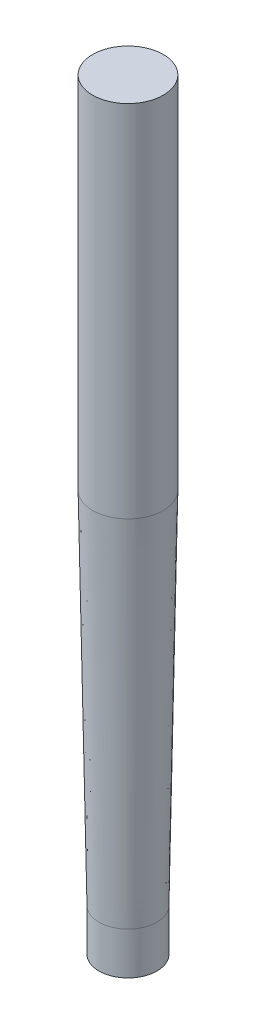
from build123d import *

# Parameters (mm, degrees)
CROQUIS2_R              = 8.341840259
SALIENTE_EXTRUIR1_DEPTH = 85
CROQUIS3_R              = 6.858159741
SALIENTE_EXTRUIR2_DEPTH = 10


with BuildPart() as part:
    # Croquis1 → Revolución1 (revolve)
    with BuildSketch(Plane(origin=(0, 0, 0), x_dir=(0, 0, -1), z_dir=(1, 0, 0))):
        Polygon((0, 0), (6.858159741, 0), (8.341840259, 85), (0, 85), align=None)
    revolve(axis=Axis((0, 0, 0), (0, 1, 0)))

    # Croquis2 → Saliente-Extruir1 (add)
    with BuildSketch(Plane(origin=(0, 85, 0), x_dir=(1, 0, 0), z_dir=(0, 1, 0))):
        Circle(CROQUIS2_R)
    extrude(amount=SALIENTE_EXTRUIR1_DEPTH)

    # Croquis3 → Saliente-Extruir2 (add)
    with BuildSketch(Plane.XZ):
        Circle(CROQUIS3_R)
    extrude(amount=SALIENTE_EXTRUIR2_DEPTH)


solid = part.part
